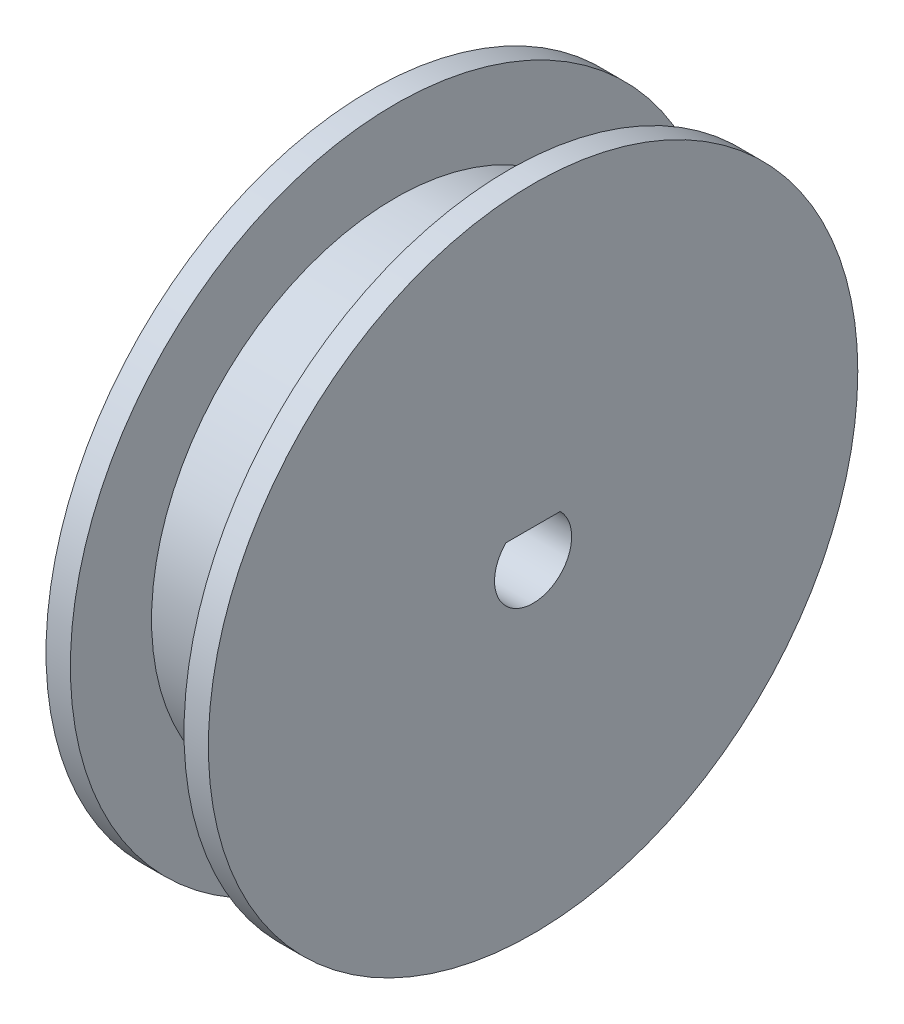
from build123d import *

# Parameters (mm, degrees)
CUT_EXTRUDE1_DEPTH = 11


with BuildPart() as part:
    # Sketch1 → Revolve1 (revolve)
    with BuildSketch(Plane.XY):
        Polygon((-5, 0), (-5, 20), (-3.5, 20), (-3.5, 15), (3.5, 15), (3.5, 20), (5, 20), (5, 0), align=None)
    revolve(axis=Axis((5, 0, 0), (-1, 0, 0)))

    # Sketch2 → Cut-Extrude1 (cut, through all)
    with BuildSketch(Plane(origin=(5, 0, 0), x_dir=(0, 0, -1), z_dir=(1, 0, 0))):
        with BuildLine():
            Line((1.66945, 1.689108258), (-1.66945, 1.689108258))
            ThreePointArc((-1.66945, 1.689108258), (-0.915252207, -2.191452351), (2.3749, 0))
            ThreePointArc((2.3749, 0), (2.191452351, 0.915252207), (1.66945, 1.689108258))
        make_face()
    extrude(amount=-CUT_EXTRUDE1_DEPTH, mode=Mode.SUBTRACT)


solid = part.part
